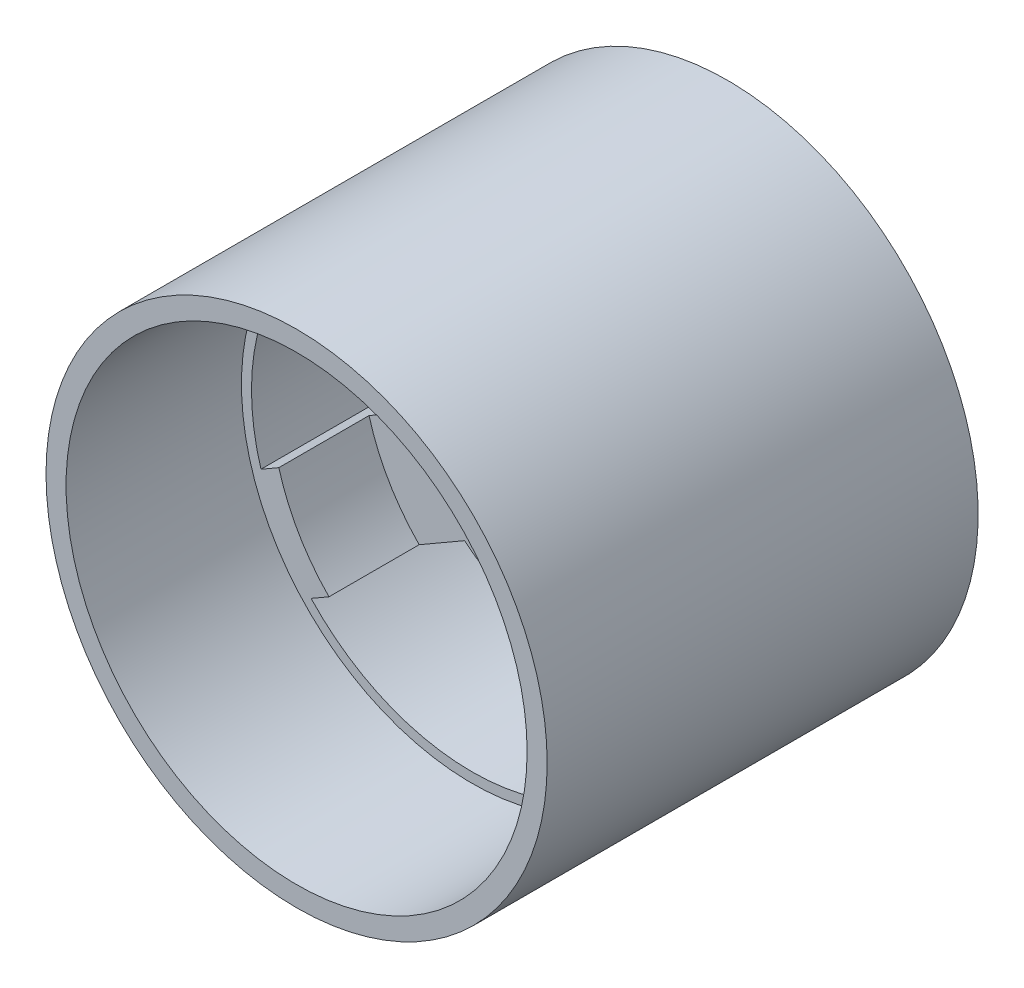
from build123d import *

# Parameters (mm, degrees)
SKETCH_1_R           = 22
SKETCH_1_R_2         = 17
EXTRUDE_1_DEPTH      = 9
SKETCH_2_R           = 22
EXTRUDE_2_DEPTH      = 3
SKETCH_3_R           = 1
CUT_EXTRUDE_1_DEPTH  = 3
CUT_EXTRUDE_2_DEPTH  = 25
SKETCH_5_R           = 4
CUT_EXTRUDE_3_DEPTH  = 10
FILLET_1_R           = 10
FILLET_2_R           = 10
SKETCH_7_R           = 25
SKETCH_7_R_2         = 22
EXTRUDE_3_DEPTH      = 30
EXTRUDE_4_DEPTH      = 4
SKETCH_9_R           = 38.67245247
CUT_EXTRUDE_4_DEPTH  = 1
SKETCH_10_R          = 25
SKETCH_10_R_2        = 22
EXTRUDE_5_DEPTH      = 13.5
SKETCH_11_R          = 23
CUT_EXTRUDE_5_DEPTH  = 10.5
CHAMFER_2_SIZE       = 1
SKETCH_12_R          = 23
CUT_EXTRUDE_6_DEPTH  = 18
SKETCH_13_R          = 39.83087954
CUT_EXTRUDE_7_DEPTH  = 2.5
SKETCH_14_R          = 15
CUT_EXTRUDE_8_DEPTH  = 0.5
SKETCH_15_R          = 25
SKETCH_15_R_2        = 23
EXTRUDE_6_DEPTH      = 2
SKETCH_16_R          = 20
CUT_EXTRUDE_9_DEPTH  = 9
SKETCH_17_R          = 20
SKETCH_17_R_2        = 1
SKETCH_17_R_3        = 4
EXTRUDE_7_DEPTH      = 2.5
SKETCH_18_R          = 1.5
CUT_EXTRUDE_10_DEPTH = 21.5
CUT_EXTRUDE_11_DEPTH = 21.5


with BuildPart() as part:
    # 草图1 → 凸台-拉伸1 (new body)
    with BuildSketch(Plane.XY):
        Circle(SKETCH_1_R)
        Circle(SKETCH_1_R_2, mode=Mode.SUBTRACT)
    extrude(amount=EXTRUDE_1_DEPTH)

    # 草图2 → 凸台-拉伸2 (add)
    with BuildSketch(Plane(origin=(0, 0, 0), x_dir=(-1, 0, 0), z_dir=(0, 0, -1))):
        Circle(SKETCH_2_R)
    extrude(amount=EXTRUDE_2_DEPTH)

    # 草图3 → 切除-拉伸1 (cut)
    with BuildSketch(Plane(origin=(0, 0, -3), x_dir=(-1, 0, 0), z_dir=(0, 0, -1))):
        with Locations((0, 10)):
            Circle(SKETCH_3_R)
        with Locations((8.660254038, -5)):
            Circle(SKETCH_3_R)
        with Locations((-8.660254038, -5)):
            Circle(SKETCH_3_R)
    extrude(amount=-CUT_EXTRUDE_1_DEPTH, mode=Mode.SUBTRACT)

    # 草图4 → 切除-拉伸2 (cut)
    with BuildSketch(Plane(origin=(0, 0, -3), x_dir=(-1, 0, 0), z_dir=(0, 0, -1))):
        Polygon((24.787699458, -8.537682263), (5, 2.886751346), (5, 15), (5, 31.006622637), (28.596284234, 19.54376122), align=None)
        Polygon((-6.160254038, -9.330127019), (0, -5.773502692), (19.787699458, -17.197936301), (-4.03507969, -32.43608202), (-23.902747272, -19.573760264), align=None)
        Polygon((-5, 10), (-5, 2.886751346), (-28.902747272, -10.913506226), (-27.638085306, 27.170625695), (-5, 31.006622637), align=None)
    extrude(amount=-CUT_EXTRUDE_2_DEPTH, mode=Mode.SUBTRACT)

    # 草图5 → 切除-拉伸3 (cut)
    with BuildSketch(Plane(origin=(0, 0, -3), x_dir=(-1, 0, 0), z_dir=(0, 0, -1))):
        Circle(SKETCH_5_R)
    extrude(amount=-CUT_EXTRUDE_3_DEPTH, mode=Mode.SUBTRACT)

    # 圆角1
    fillet_1_edges = [part.edges().sort_by_distance(p)[0] for p in [
        (-5, 2.886751346, -1.5),
    ]]
    fillet(fillet_1_edges, radius=FILLET_1_R)

    # 圆角2
    fillet_2_edges = [part.edges().sort_by_distance(p)[0] for p in [
        (5, 2.886751346, -1.5),
        (0, -5.773502692, -1.5),
    ]]
    fillet(fillet_2_edges, radius=FILLET_2_R)

    # 草图7 → 凸台-拉伸3 (add)
    with BuildSketch(Plane(origin=(0, 0, -3), x_dir=(-1, 0, 0), z_dir=(0, 0, -1))):
        Circle(SKETCH_7_R)
        Circle(SKETCH_7_R_2, mode=Mode.SUBTRACT)
    extrude(amount=-EXTRUDE_3_DEPTH)

    # 草图8 → 凸台-拉伸4 (add)
    with BuildSketch(Plane(origin=(0, 0, -3), x_dir=(-1, 0, 0), z_dir=(0, 0, -1))):
        with BuildLine():
            Line((-21.053975315, -6.382015624), (-15.753584421, -3.321833514))
            ThreePointArc((-15.753584421, -3.321833514), (-13.943009001, -8.05), (-10.753584421, -11.982087552))
            Line((-10.753584421, -11.982087552), (-16.053975315, -15.042269662))
            ThreePointArc((-16.053975315, -15.042269662), (-19.052558883, -11), (-21.053975315, -6.382015624))
        make_face()
        with BuildLine():
            Line((16.053975315, -15.042269662), (10.753584421, -11.982087552))
            ThreePointArc((10.753584421, -11.982087552), (13.943009001, -8.05), (15.753584421, -3.321833514))
            Line((15.753584421, -3.321833514), (21.053975315, -6.382015624))
            ThreePointArc((21.053975315, -6.382015624), (19.052558883, -11), (16.053975315, -15.042269662))
        make_face()
        with BuildLine():
            Line((5, 21.424285286), (5, 15.303921066))
            ThreePointArc((5, 15.303921066), (0, 16.1), (-5, 15.303921066))
            Line((-5, 15.303921066), (-5, 21.424285286))
            ThreePointArc((-5, 21.424285286), (0, 22), (5, 21.424285286))
        make_face()
    extrude(amount=EXTRUDE_4_DEPTH)

    # 草图9 → 切除-拉伸4 (cut)
    with BuildSketch(Plane(origin=(0, 0, -7), x_dir=(-1, 0, 0), z_dir=(0, 0, -1))):
        Circle(SKETCH_9_R)
    extrude(amount=-CUT_EXTRUDE_4_DEPTH, mode=Mode.SUBTRACT)

    # 草图10 → 凸台-拉伸5 (add)
    with BuildSketch(Plane(origin=(0, 0, -3), x_dir=(-1, 0, 0), z_dir=(0, 0, -1))):
        Circle(SKETCH_10_R)
        Circle(SKETCH_10_R_2, mode=Mode.SUBTRACT)
    extrude(amount=EXTRUDE_5_DEPTH)

    # 草图11 → 切除-拉伸5 (cut)
    with BuildSketch(Plane(origin=(0, 0, -16.5), x_dir=(-1, 0, 0), z_dir=(0, 0, -1))):
        Circle(SKETCH_11_R)
    extrude(amount=-CUT_EXTRUDE_5_DEPTH, mode=Mode.SUBTRACT)

    # 倒角2
    chamfer_2_edges = [part.edges().sort_by_distance(p)[0] for p in [
        (23, 0, -16.5),
    ]]
    chamfer(chamfer_2_edges, length=CHAMFER_2_SIZE)

    # 草图12 → 切除-拉伸6 (cut)
    with BuildSketch(Plane.XY.offset(27)):
        Circle(SKETCH_12_R)
    extrude(amount=-CUT_EXTRUDE_6_DEPTH, mode=Mode.SUBTRACT)

    # 草图13 → 切除-拉伸7 (cut)
    with BuildSketch(Plane.XY.offset(27)):
        Circle(SKETCH_13_R)
    extrude(amount=-CUT_EXTRUDE_7_DEPTH, mode=Mode.SUBTRACT)

    # 草图14 → 切除-拉伸8 (cut)
    with BuildSketch(Plane(origin=(0, 0, -3), x_dir=(-1, 0, 0), z_dir=(0, 0, -1))):
        Circle(SKETCH_14_R)
    extrude(amount=-CUT_EXTRUDE_8_DEPTH, mode=Mode.SUBTRACT)

    # 草图15 → 凸台-拉伸6 (add)
    with BuildSketch(Plane.XY.offset(24.5)):
        Circle(SKETCH_15_R)
        Circle(SKETCH_15_R_2, mode=Mode.SUBTRACT)
    extrude(amount=EXTRUDE_6_DEPTH)

    # 草图16 → 切除-拉伸9 (cut)
    with BuildSketch(Plane.XY.offset(9)):
        Circle(SKETCH_16_R)
    extrude(amount=-CUT_EXTRUDE_9_DEPTH, mode=Mode.SUBTRACT)

    # 草图17 → 凸台-拉伸7 (add)
    with BuildSketch(Plane.XY):
        Circle(SKETCH_17_R)
        with Locations((8.660254038, -5)):
            Circle(SKETCH_17_R_2, mode=Mode.SUBTRACT)
        with Locations((-8.660254038, -5)):
            Circle(SKETCH_17_R_2, mode=Mode.SUBTRACT)
        with Locations((0, 10)):
            Circle(SKETCH_17_R_2, mode=Mode.SUBTRACT)
        Circle(SKETCH_17_R_3, mode=Mode.SUBTRACT)
    extrude(amount=-EXTRUDE_7_DEPTH)

    # 草图18 → 切除-拉伸10 (cut)
    with BuildSketch(Plane(origin=(0, 0, -2.5), x_dir=(-1, 0, 0), z_dir=(0, 0, -1))):
        with Locations((-6.92603443, -4.003754122)):
            Circle(SKETCH_18_R)
        with Locations((-4.003754122, 6.92603443)):
            Circle(SKETCH_18_R)
        with Locations((6.92603443, 4.003754122)):
            Circle(SKETCH_18_R)
        with Locations((4.003754122, -6.92603443)):
            Circle(SKETCH_18_R)
    extrude(amount=-CUT_EXTRUDE_10_DEPTH, mode=Mode.SUBTRACT)

    # 草图19 → 切除-拉伸11 (cut)
    with BuildSketch(Plane(origin=(0, 0, -2.5), x_dir=(-1, 0, 0), z_dir=(0, 0, -1))):
        with BuildLine():
            Line((-19.986274047, -5.765578009), (-14.740678373, -2.737031935))
            ThreePointArc((-14.740678373, -2.737031935), (-12.983998114, 7.496314806), (-5, 14.134317907))
            Line((-5, 14.134317907), (-5, 20.191410056))
            ThreePointArc((-5, 20.191410056), (-18.014432548, 10.400637481), (-19.986274047, -5.765578009))
        make_face()
        with BuildLine():
            Line((5, 20.191410056), (5, 14.134317907))
            ThreePointArc((5, 14.134317907), (12.983998114, 7.496314806), (14.740678373, -2.737031935))
            Line((14.740678373, -2.737031935), (19.986274047, -5.765578009))
            ThreePointArc((19.986274047, -5.765578009), (18.014432548, 10.400637481), (5, 20.191410056))
        make_face()
        with BuildLine():
            Line((14.986274047, -14.425832047), (9.740678373, -11.397285972))
            ThreePointArc((9.740678373, -11.397285972), (0, -14.992629613), (-9.740678373, -11.397285972))
            Line((-9.740678373, -11.397285972), (-14.986274047, -14.425832047))
            ThreePointArc((-14.986274047, -14.425832047), (0, -20.801274962), (14.986274047, -14.425832047))
        make_face()
    extrude(amount=-CUT_EXTRUDE_11_DEPTH, mode=Mode.SUBTRACT)


solid = part.part
